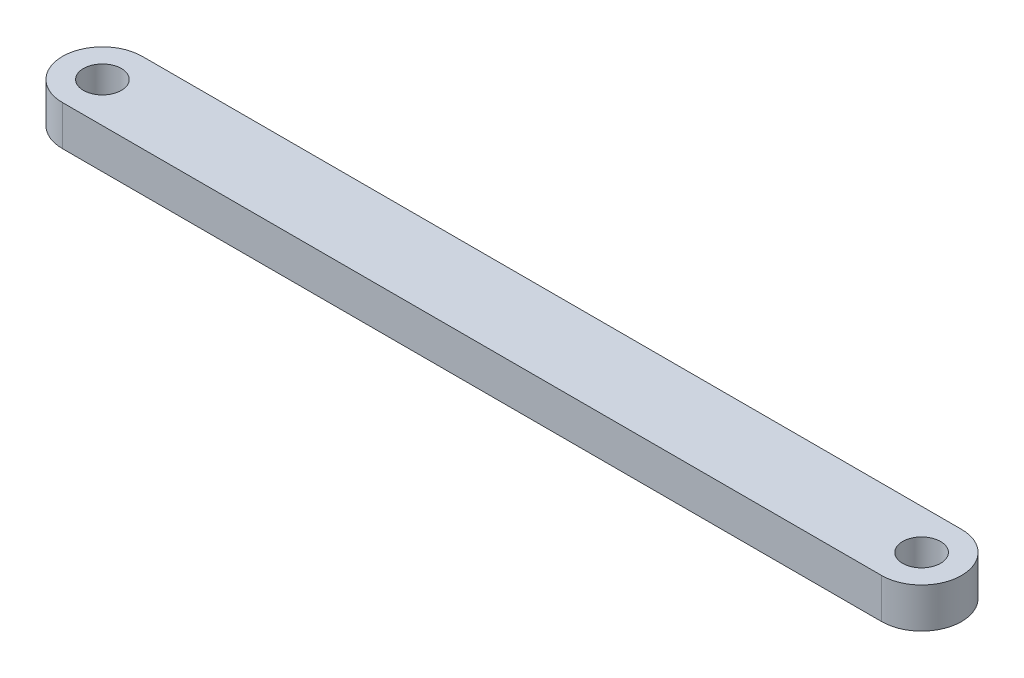
from build123d import *

# Parameters (mm, degrees)
SKETCH1_R           = 4.75
BOSS_EXTRUDE1_DEPTH = 10


with BuildPart() as part:
    # Sketch1 → Boss-Extrude1 (new body)
    with BuildSketch(Plane(origin=(0, 0, 0), x_dir=(1, 0, 0), z_dir=(0, 1, 0))):
        with BuildLine():
            Line((102.5, -10), (-102.5, -10))
            ThreePointArc((-102.5, -10), (-112.5, 0), (-102.5, 10))
            Line((-102.5, 10), (102.5, 10))
            ThreePointArc((102.5, 10), (112.5, 0), (102.5, -10))
        make_face()
        with Locations((-102.5, 0)):
            Circle(SKETCH1_R, mode=Mode.SUBTRACT)
        with Locations((102.5, 0)):
            Circle(SKETCH1_R, mode=Mode.SUBTRACT)
    extrude(amount=BOSS_EXTRUDE1_DEPTH)


solid = part.part
